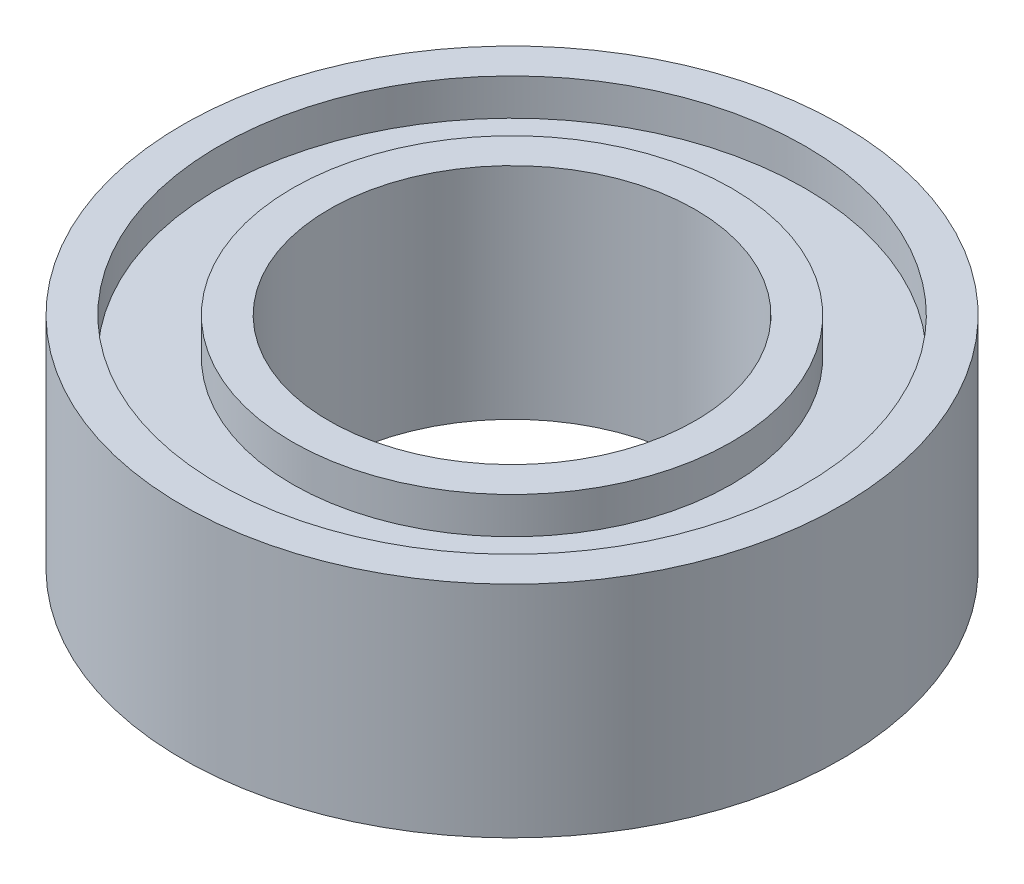
from build123d import *


with BuildPart() as part:
    # Sketch1 → Revolve1 (revolve)
    with BuildSketch(Plane.XY):
        Polygon((-2.5, 2.5), (-3, 2.5), (-3, 2), (-4, 2), (-4, 2.5), (-4.5, 2.5), (-4.5, -0.5), (-4, -0.5), (-4, 0), (-3, 0), (-3, -0.5), (-2.5, -0.5), align=None)
    revolve(axis=Axis((0, 0, 0), (0, 1, 0)))


solid = part.part
